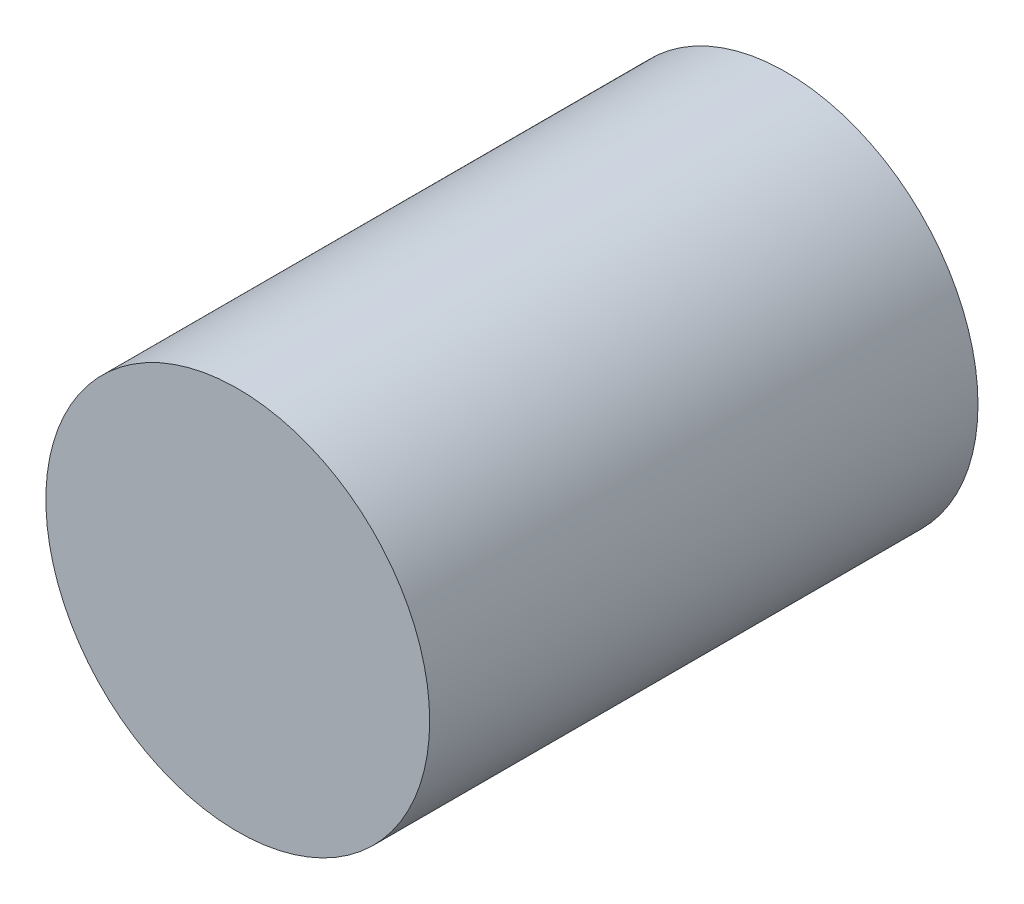
from build123d import *

# Parameters (mm, degrees)
SKETCH1_R           = 3.5
BOSS_EXTRUDE1_DEPTH = 10


with BuildPart() as part:
    # Sketch1 → Boss-Extrude1 (new body)
    with BuildSketch(Plane.XY):
        Circle(SKETCH1_R)
    extrude(amount=BOSS_EXTRUDE1_DEPTH)


solid = part.part
